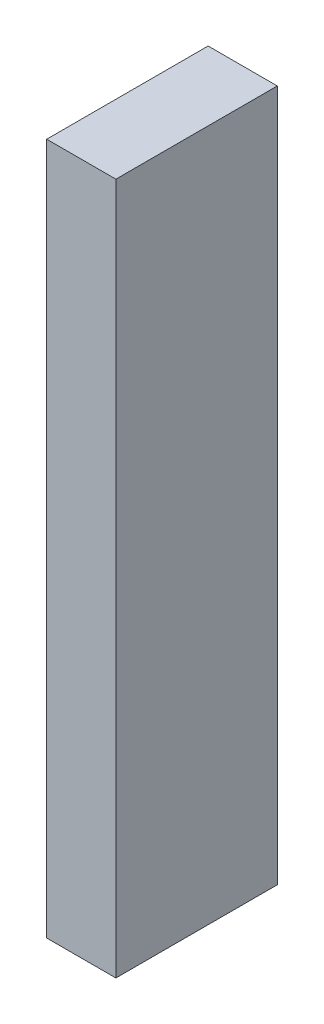
from build123d import *

# Parameters (mm, degrees)
SKETCH1_W           = 88.9
SKETCH1_H           = 304.8
SKETCH1_H_2         = 76.2
BOSS_EXTRUDE1_DEPTH = 38.1


with BuildPart() as part:
    # Sketch1 → Boss-Extrude1 (new body)
    with BuildSketch(Plane(origin=(0, 0, 0), x_dir=(0, 0, -1), z_dir=(1, 0, 0))):
        with Locations((44.45, 152.4)):
            Rectangle(SKETCH1_W, SKETCH1_H)
        with Locations((44.45, 342.9)):
            Rectangle(SKETCH1_W, SKETCH1_H_2)
    extrude(amount=BOSS_EXTRUDE1_DEPTH)


solid = part.part
